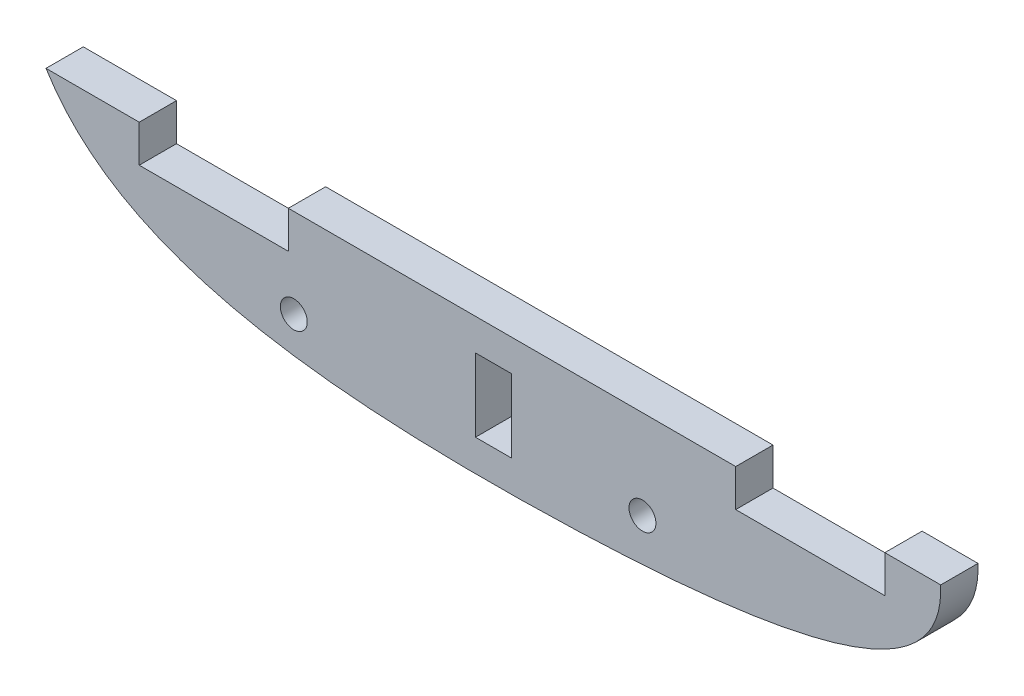
from build123d import *

# Parameters (mm, degrees)
SKETCH1_R           = 2.29235
SKETCH1_W           = 6.096
SKETCH1_H           = 12.446
BOSS_EXTRUDE1_DEPTH = 6.35


with BuildPart() as part:
    # Sketch1 → Boss-Extrude1 (new body)
    with BuildSketch(Plane.XY):
        with BuildLine():
            Line((0, 23.24229762), (15.880645326, 23.24229762))
            Line((15.880645326, 23.24229762), (15.880645326, 16.89229762))
            Line((15.880645326, 16.89229762), (41.280645326, 16.89229762))
            Line((41.280645326, 16.89229762), (41.280645326, 23.24229762))
            Line((41.280645326, 23.24229762), (117.480645326, 23.24229762))
            Line((117.480645326, 23.24229762), (117.480645326, 16.89229762))
            Line((117.480645326, 16.89229762), (142.880645326, 16.89229762))
            Line((142.880645326, 16.89229762), (142.880645326, 23.24229762))
            Line((142.880645326, 23.24229762), (152.4, 23.24229762))
            add(Edge.make_bspline(
                [(0, 23.24229762), (9.595728413, 7.571672257), (37.691629547, -0.62330484), (137.924513907, 0.735082948), (152.821327453, 10.851345908), (152.4, 23.24229762)],
                knots=[0, 0, 0, 0, 0.362368997, 0.462368997, 1, 1, 1, 1], degree=3))
        make_face()
        with Locations((101.6, 8.067795146)):
            Circle(SKETCH1_R, mode=Mode.SUBTRACT)
        with Locations((42.207808654, 8.067795146)):
            Circle(SKETCH1_R, mode=Mode.SUBTRACT)
        with Locations((76.2, 11.62114881)):
            Rectangle(SKETCH1_W, SKETCH1_H, mode=Mode.SUBTRACT)
    extrude(amount=BOSS_EXTRUDE1_DEPTH)


solid = part.part
